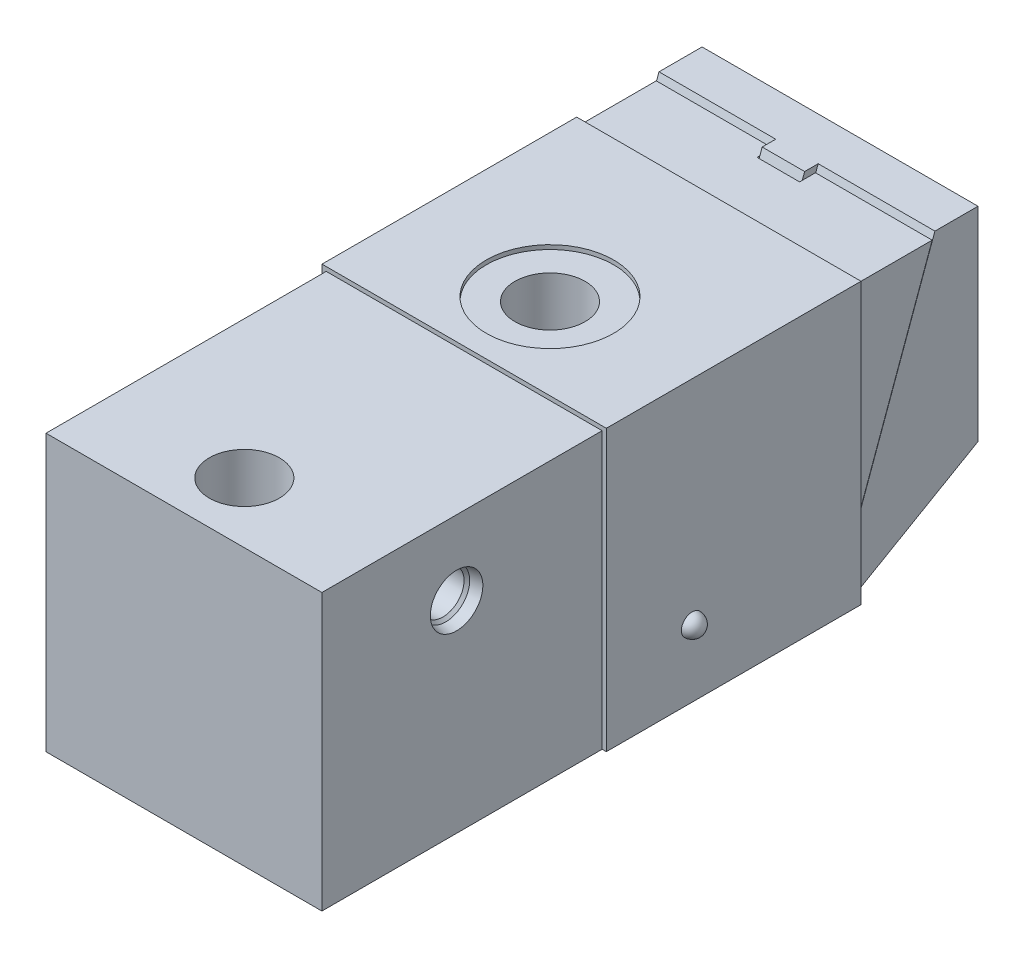
from build123d import *

# Parameters (mm, degrees)
SKETCH1_W          = 107.0102
SKETCH1_H          = 64.9986
EXTRUDE1_DEPTH     = 32.4993
EXTRUDE4_DEPTH     = 32.500062
EXTRUDE5_DEPTH     = 4.99999
SKETCH14_R         = 5.0038
EXTRUDE6_DEPTH     = 5.9944
CUT_EXTRUDE3_DEPTH = 5.9944
EXTRUDE2_DEPTH     = 32.4993
CUT_EXTRUDE1_DEPTH = 5.0038
SKETCH4_R          = 8.255
CUT_EXTRUDE2_DEPTH = 64.9986
HOLE1_AT_2_COUNT   = 2
HOLE1_AT_2_PITCH   = 83.0072
HOLE1_AT_3_COUNT   = 2
HOLE1_AT_3_PITCH   = 46.99
HOLE1_AT_4_COUNT   = 2
HOLE1_AT_4_PITCH   = 95.384775262
SKETCH8_R          = 1.0033
EXTRUDE3_DEPTH     = 59.9948
SKETCH18_R         = 14.9987
CUT_EXTRUDE4_DEPTH = 0.9906
SKETCH20_R         = 16.002
CUT_EXTRUDE5_DEPTH = 5.842


with BuildPart() as part:
    # Sketch1 → Extrude1 (new body, symmetric)
    with BuildSketch(Plane(origin=(0, 0, 0), x_dir=(0, 0, -1), z_dir=(1, 0, 0))):
        with Locations((53.5051, 32.4993)):
            Rectangle(SKETCH1_W, SKETCH1_H)
    extrude(amount=EXTRUDE1_DEPTH, both=True)

    # Sketch4 → Cut-Extrude2 (cut)
    with BuildSketch(Plane.XZ):
        with Locations(Location((0, -14.224, 0), (0, 0, 270))):  # turned: the seam where the file's is
            Circle(SKETCH4_R)
        with Locations(Location((0, -86.233, 0), (0, 0, 270))):  # turned: the seam where the file's is
            Circle(SKETCH4_R)
    extrude(amount=-CUT_EXTRUDE2_DEPTH, mode=Mode.SUBTRACT)

    # Sketch16 → Hole1 (revolve, cut)
    with BuildSketch(Plane(origin=(-23.495, 0, -14.224), x_dir=(0, 0, -1), z_dir=(1, 0, 0))):
        Polygon((0, 0), (0, 19.008586365), (5.0038, 16.002), (5.0038, 0), align=None)
    hole1 = revolve(axis=Axis((-23.495, -4.244199587, -14.224), (0, 1, 0)), mode=Mode.SUBTRACT)

    # Hole1 at 2: Hole1 ×2
    with Locations(*[(0, 0, -i * HOLE1_AT_2_PITCH) for i in range(1, HOLE1_AT_2_COUNT)]):
        add(hole1, mode=Mode.SUBTRACT)

    # Hole1 at 3: Hole1 ×2
    with Locations(*[(i * HOLE1_AT_3_PITCH, 0, 0) for i in range(1, HOLE1_AT_3_COUNT)]):
        add(hole1, mode=Mode.SUBTRACT)

    # Hole1 at 4: Hole1 ×2
    with Locations(*[Vector(0.492636271, 0, -0.870235316) * (i * HOLE1_AT_4_PITCH) for i in range(1, HOLE1_AT_4_COUNT)]):
        add(hole1, mode=Mode.SUBTRACT)

    # S2D0001 → Cut-Revolve2 (revolve, cut)
    with BuildSketch(Plane(origin=(14.986, 47.498, -21.336), x_dir=(0, 0, -1), z_dir=(0, -1, 0)), mode=Mode.PRIVATE) as cut_revolve2_sk:
        Polygon((10.3886, 17.5133), (16.5735, 17.5133), (16.030906865, 14.9606), (15.367, 14.296693135), (15.367, -20.5867), (10.3886, -20.5867), align=None)
    cut_revolve2 = revolve(cut_revolve2_sk.sketch.rotate(Axis((-10.40039223, 47.498, -31.7246), (1, 0, 0)), 180), axis=Axis((-10.40039223, 47.498, -31.7246), (1, 0, 0)), mode=Mode.SUBTRACT)  # turned: the seam where the file's is

    # Mirror1: Cut-Revolve2 across plane
    add(cut_revolve2.mirror(Plane(origin=(0, 0, 0), x_dir=(0, 0, 1), z_dir=(1, 0, 0))), mode=Mode.SUBTRACT)

    # Sketch19 → Cut-Revolve5 (revolve, cut)
    with BuildSketch(Plane(origin=(0, 0, 0), x_dir=(0, 0, -1), z_dir=(1, 0, 0)), mode=Mode.PRIVATE) as cut_revolve5_sk:
        Polygon((36.0426, 0), (36.0426, 1.5875), (34.2265, 1.5875), (34.2265, 47.498), (31.7246, 47.498), (31.7246, 0), align=None)
    revolve(cut_revolve5_sk.sketch.rotate(Axis((0, 47.498, -31.7246), (0, -1, 0)), 180), axis=Axis((0, 47.498, -31.7246), (0, -1, 0)), mode=Mode.SUBTRACT)  # turned: the seam where the file's is

    # Sketch20 → Cut-Extrude5 (cut)
    with BuildSketch(Plane.XZ):
        with Locations(Location((0, -86.233, 0), (0, 0, 270))):  # turned: the seam where the file's is
            Circle(SKETCH20_R)
    extrude(amount=-CUT_EXTRUDE5_DEPTH, mode=Mode.SUBTRACT)


with BuildPart() as body_2:
    # Sketch11 → Extrude4 (new body, symmetric)
    with BuildSketch(Plane(origin=(0, 0, 0), x_dir=(0, 0, -1), z_dir=(1, 0, 0))):
        Polygon((144.409668, 66.5226), (154.559, 66.5226), (154.559, 18.5166), (125.126953447, 1.524), (120.752112331, 1.524), align=None)
    extrude(amount=EXTRUDE4_DEPTH, both=True)

    # Sketch12 → Extrude5 (add, symmetric)
    with BuildSketch(Plane(origin=(0, 0, 0), x_dir=(0, 0, -1), z_dir=(1, 0, 0))):
        Polygon((144.409668, 66.5226), (120.752112331, 1.524), (117.559585399, 1.524), (141.217141068, 66.5226), align=None)
    extrude(amount=EXTRUDE5_DEPTH, both=True)

    # Sketch13 → Cut-Revolve4 (revolve, cut)
    with BuildSketch(Plane(origin=(0, 0, 0), x_dir=(0, 0, -1), z_dir=(1, 0, 0)), mode=Mode.PRIVATE) as cut_revolve4_sk:
        Polygon((154.559, 36.524057), (147.25904, 36.524057), (147.25904, 34.124011), (142.6591, 34.124011), (142.6591, 44.024042), (110.9091, 44.024042), (110.9091, 31.024068), (154.559, 31.024068), align=None)
    revolve(cut_revolve4_sk.sketch.rotate(Axis((0, 31.024068, -76.857343905), (0, 0, -1)), 90), axis=Axis((0, 31.024068, -76.857343905), (0, 0, -1)), mode=Mode.SUBTRACT)  # turned: the seam where the file's is

    # Sketch14 → Extrude6 (add)
    with BuildSketch(Plane(origin=(0, 0, -147.25904), x_dir=(-1, 0, 0), z_dir=(0, 0, -1))):
        with Locations((0, 31.024068)):
            Circle(SKETCH14_R)
    extrude(amount=EXTRUDE6_DEPTH)

    # Sketch15 → Cut-Extrude3 (cut)
    with BuildSketch(Plane(origin=(0, 0, -153.25344), x_dir=(-1, 0, 0), z_dir=(0, 0, -1))):
        Polygon((3.460868454, 31.024068), (1.730434227, 34.021268), (-1.730434227, 34.021268), (-3.460868454, 31.024068), (-1.730434227, 28.026868), (1.730434227, 28.026868), align=None)
    extrude(amount=-CUT_EXTRUDE3_DEPTH, mode=Mode.SUBTRACT)


with BuildPart() as body_3:
    # Sketch2 → Extrude2 (new body, symmetric)
    with BuildSketch(Plane(origin=(0, 0, 0), x_dir=(0, 0, -1), z_dir=(1, 0, 0))):
        Polygon((113.259296777, 64.9986), (113.259296777, 2.0066), (120.837483781, 2.0066), (143.764696777, 64.9986), align=None)
    extrude(amount=EXTRUDE2_DEPTH, both=True)

    # Sketch3 → Cut-Extrude1 (cut, symmetric)
    with BuildSketch(Plane(origin=(0, 0, 0), x_dir=(0, 0, -1), z_dir=(1, 0, 0))):
        Polygon((140.030896777, 64.9986), (117.103683781, 2.0066), (120.837483781, 2.0066), (143.764696777, 64.9986), align=None)
    extrude(amount=CUT_EXTRUDE1_DEPTH, both=True, mode=Mode.SUBTRACT)


with BuildPart() as body_4:
    # Sketch8 → Revolve1 (revolve)
    with BuildSketch(Plane(origin=(0, 0, 0), x_dir=(0, 0, -1), z_dir=(1, 0, 0)), mode=Mode.PRIVATE) as revolve1_sk:
        with Locations((35.0393, 0.5842)):
            Circle(SKETCH8_R)
    revolve(revolve1_sk.sketch.rotate(Axis((0, -0.51943, -31.7246), (0, 1, 0)), 180), axis=Axis((0, -0.51943, -31.7246), (0, 1, 0)))  # turned: the seam where the file's is


with BuildPart() as body_5:
    # Sketch9 → Extrude3 (new body)
    with BuildSketch(Plane(origin=(0, 0, -126.0094), x_dir=(-1, 0, 0), z_dir=(0, 0, -1))):
        Polygon((32.4993, 64.9986), (32.4993, 0), (33.4899, 0), (33.4899, 65.9892), (-33.4899, 65.9892), (-33.4899, 0), (-32.4993, 0), (-32.4993, 64.9986), align=None)
    extrude(amount=-EXTRUDE3_DEPTH)

    # Sketch10 → Revolve2 (revolve)
    with BuildSketch(Plane(origin=(0, 15.875, -83.7438), x_dir=(1, 0, 0), z_dir=(0, 1, 0))):
        with BuildLine():
            Line((33.4899, 5.0292), (33.4899, 2.4892))
            Line((33.4899, 2.4892), (36.0299, 2.4892))
            ThreePointArc((36.0299, 2.4892), (35.285951224, 4.285251224), (33.4899, 5.0292))
        make_face()
        with BuildLine():
            Line((-33.4899, 5.0292), (-33.4899, 2.4892))
            Line((-33.4899, 2.4892), (-36.0299, 2.4892))
            ThreePointArc((-36.0299, 2.4892), (-35.285951224, 4.285251224), (-33.4899, 5.0292))
        make_face()
    revolve(axis=Axis((-20.36826, 15.875, -86.233), (1, 0, 0)))

    # Sketch18 → Cut-Extrude4 (cut)
    with BuildSketch(Plane(origin=(0, 65.9892, 0), x_dir=(1, 0, 0), z_dir=(0, 1, 0))):
        with Locations(Location((0, 86.233, 0), (0, 0, 180))):  # turned: the seam where the file's is
            Circle(SKETCH18_R)
    extrude(amount=-CUT_EXTRUDE4_DEPTH, mode=Mode.SUBTRACT)


solid = Compound([part.part, body_2.part, body_3.part, body_4.part, body_5.part])
